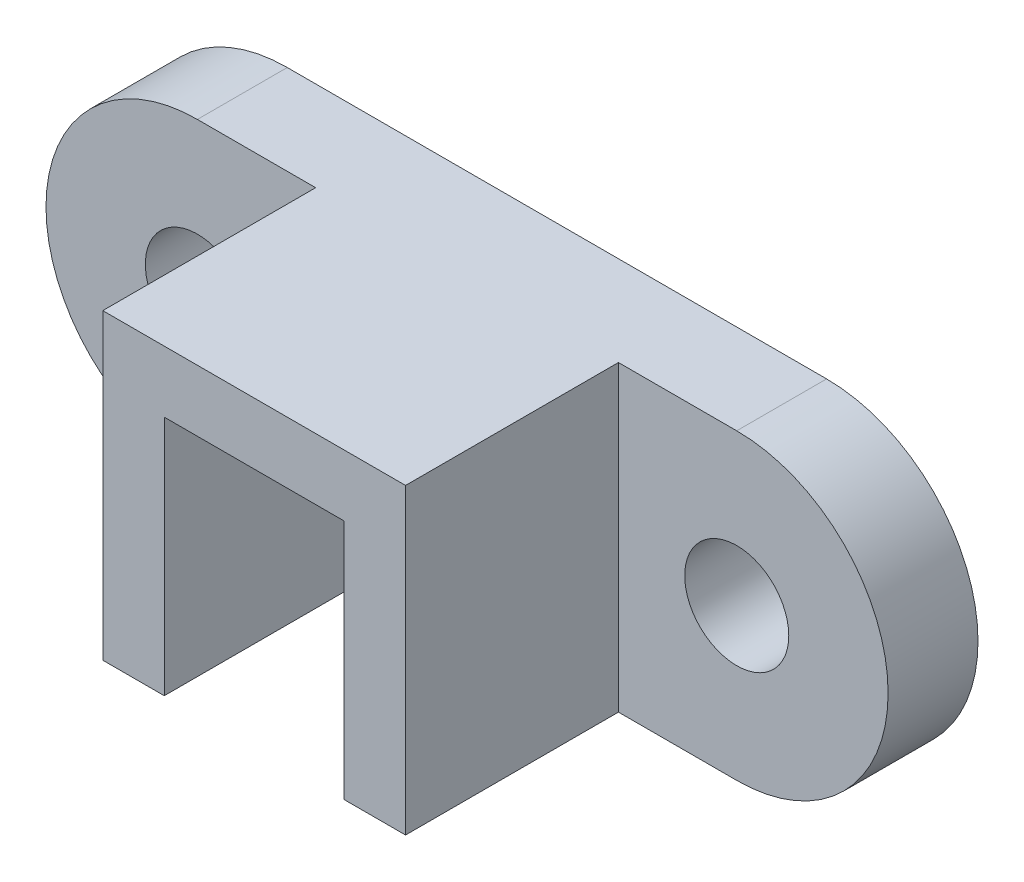
from build123d import *

# Parameters (mm, degrees)
BOSS_EXTRUDE1_DEPTH = 19
SKETCH2_R           = 11
CUT_EXTRUDE1_DEPTH  = 20
SKETCH5_W           = 32
SKETCH5_H           = 64
BOSS_EXTRUDE4_DEPTH = 45
CUT_EXTRUDE3_DEPTH  = 19


with BuildPart() as part:
    # Sketch1 → Boss-Extrude1 (new body)
    with BuildSketch(Plane.XY):
        with BuildLine():
            Line((-57, 32), (57, 32))
            ThreePointArc((57, 32), (89, 0), (57, -32))
            Line((57, -32), (-57, -32))
            ThreePointArc((-57, -32), (-89, 0), (-57, 32))
        make_face()
    extrude(amount=BOSS_EXTRUDE1_DEPTH)

    # Sketch2 → Cut-Extrude1 (cut, through all)
    with BuildSketch(Plane.XY.offset(19)):
        with Locations((-57, 0)):
            Circle(SKETCH2_R)
        with Locations((57, 0)):
            Circle(SKETCH2_R)
    extrude(amount=-CUT_EXTRUDE1_DEPTH, mode=Mode.SUBTRACT)

    # Sketch5 → Boss-Extrude4 (add)
    with BuildSketch(Plane.XY.offset(19)):
        with Locations((-16, 0)):
            Rectangle(SKETCH5_W, SKETCH5_H)
    boss_extrude4 = extrude(amount=BOSS_EXTRUDE4_DEPTH)

    # Sketch8 → Cut-Extrude3 (cut)
    with BuildSketch(Plane(origin=(0, 0, 0), x_dir=(0, 0, -1), z_dir=(1, 0, 0))):
        Polygon((-13, -32), (-64, 19), (-64, -32), align=None)
    cut_extrude3 = extrude(amount=-CUT_EXTRUDE3_DEPTH, mode=Mode.SUBTRACT)

    # Mirror2: Boss-Extrude4, Cut-Extrude3 across plane
    add(boss_extrude4.mirror(Plane(origin=(0, 0, 0), x_dir=(0, 0, 1), z_dir=(1, 0, 0))))
    add(cut_extrude3.mirror(Plane(origin=(0, 0, 0), x_dir=(0, 0, 1), z_dir=(1, 0, 0))), mode=Mode.SUBTRACT)


solid = part.part
